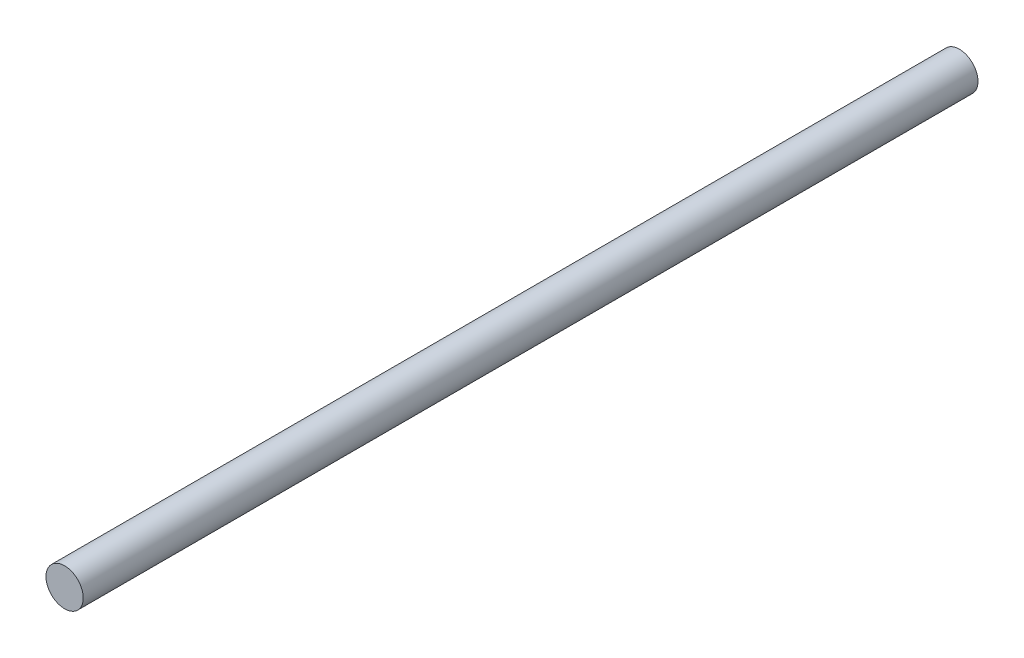
from build123d import *

# Parameters (mm, degrees)
SKETCH1_R           = 1
BOSS_EXTRUDE1_DEPTH = 48


with BuildPart() as part:
    # Sketch1 → Boss-Extrude1 (new body)
    with BuildSketch(Plane.XY):
        Circle(SKETCH1_R)
    extrude(amount=BOSS_EXTRUDE1_DEPTH)


solid = part.part
